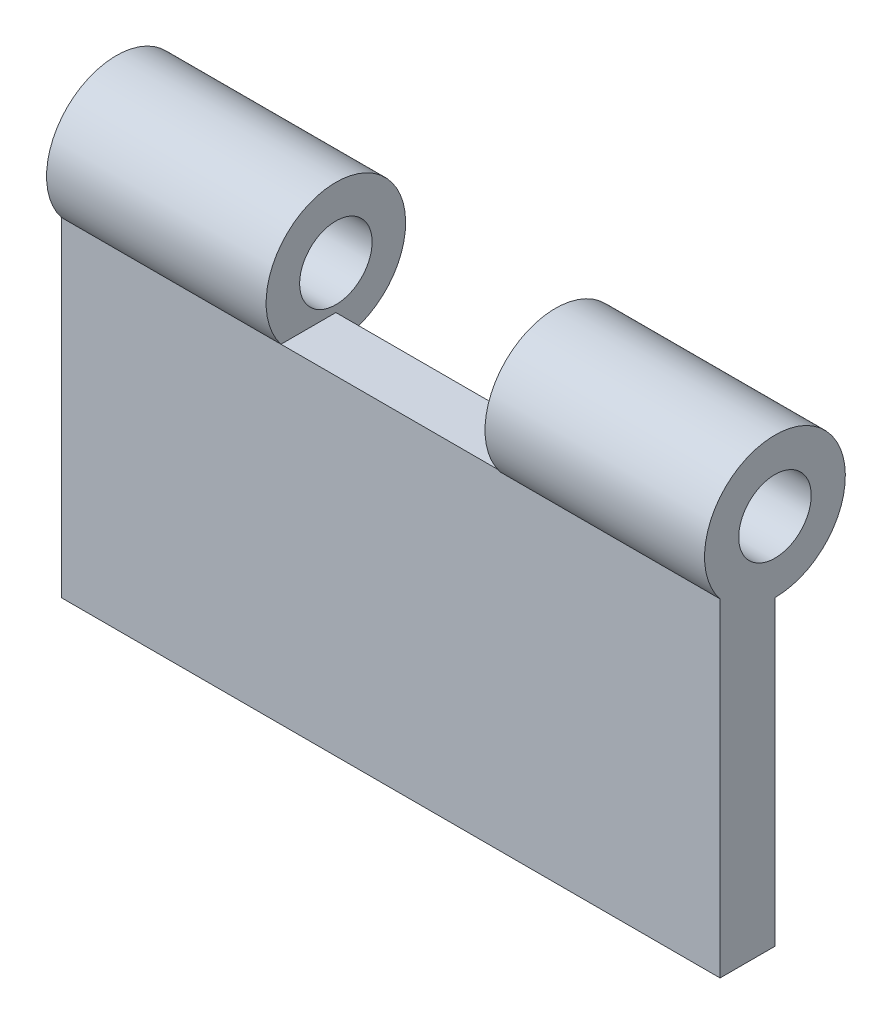
from build123d import *

# Parameters (mm, degrees)
SKETCH1_W           = 60
SKETCH1_H           = 30
BOSS_EXTRUDE1_DEPTH = 5
SKETCH2_R           = 6.41363938
SKETCH2_R_2         = 3.302926723
BOSS_EXTRUDE2_DEPTH = 20
SKETCH3_R           = 6.356146431
SKETCH3_R_2         = 3.302926723
BOSS_EXTRUDE3_DEPTH = 20


with BuildPart() as part:
    # Sketch1 → Boss-Extrude1 (new body)
    with BuildSketch(Plane.XY):
        with Locations((30, -15)):
            Rectangle(SKETCH1_W, SKETCH1_H)
    extrude(amount=BOSS_EXTRUDE1_DEPTH)

    # Sketch2 → Boss-Extrude2 (add)
    with BuildSketch(Plane(origin=(60, 0, 0), x_dir=(0, 0, -1), z_dir=(1, 0, 0))):
        with Locations((0, 3.924359496)):
            Circle(SKETCH2_R)
        with Locations((0, 3.924359496)):
            Circle(SKETCH2_R_2, mode=Mode.SUBTRACT)
    extrude(amount=-BOSS_EXTRUDE2_DEPTH)

    # Sketch3 → Boss-Extrude3 (add)
    with BuildSketch(Plane.ZY):
        with Locations((0, 3.924359496)):
            Circle(SKETCH3_R)
        with Locations((0, 3.924359496)):
            Circle(SKETCH3_R_2, mode=Mode.SUBTRACT)
    extrude(amount=-BOSS_EXTRUDE3_DEPTH)


solid = part.part
